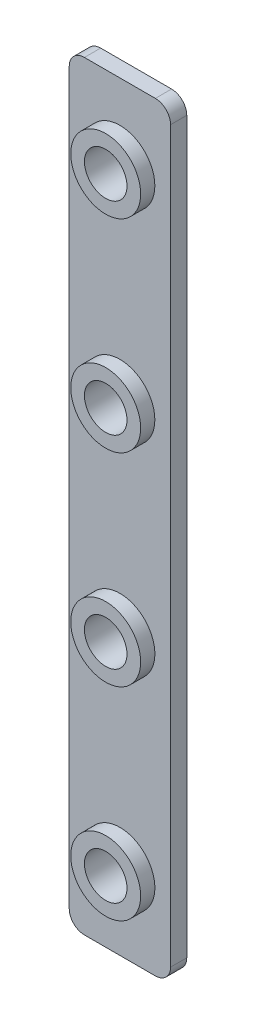
from build123d import *

# Parameters (mm, degrees)
BOSS_EXTRUDE1_DEPTH   = 1.6
SKETCH2_R             = 3.45
BOSS_EXTRUDE2_DEPTH   = 1.4
M5X0_8_TAPPED_HOLE1_D = 4.2


with BuildPart() as part:
    # Sketch1 → Boss-Extrude1 (new body)
    with BuildSketch(Plane.XY):
        with BuildLine():
            Line((3.5, -37.5), (-3.5, -37.5))
            ThreePointArc((-3.5, -37.5), (-4.560660172, -37.060660172), (-5, -36))
            Line((-5, -36), (-5, 36))
            ThreePointArc((-5, 36), (-4.560660172, 37.060660172), (-3.5, 37.5))
            Line((-3.5, 37.5), (3.5, 37.5))
            ThreePointArc((3.5, 37.5), (4.560660172, 37.060660172), (5, 36))
            Line((5, 36), (5, -36))
            ThreePointArc((5, -36), (4.560660172, -37.060660172), (3.5, -37.5))
        make_face()
    extrude(amount=BOSS_EXTRUDE1_DEPTH)

    # Sketch2 → Boss-Extrude2 (add)
    with BuildSketch(Plane.XY.offset(1.6)):
        with Locations((0, 10)):
            Circle(SKETCH2_R)
        with Locations((0, 30)):
            Circle(SKETCH2_R)
        with Locations((0, -10)):
            Circle(SKETCH2_R)
        with Locations((0, -30)):
            Circle(SKETCH2_R)
    extrude(amount=BOSS_EXTRUDE2_DEPTH)

    # M5x0.8 Tapped Hole1 (through all)
    with Locations(Plane.XY.offset(3)):
        with Locations((0, 30), (0, 10), (0, -10), (0, -30)):
            Hole(M5X0_8_TAPPED_HOLE1_D / 2)


solid = part.part
